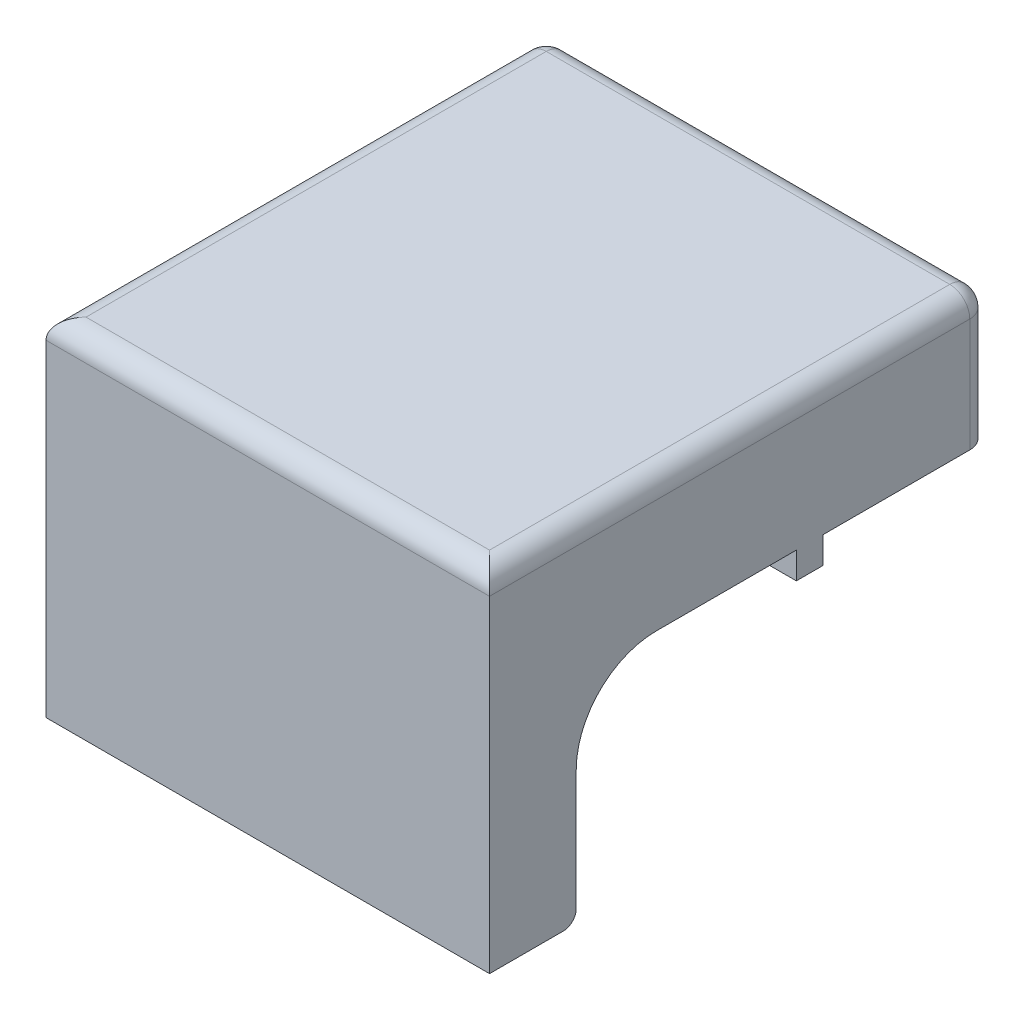
from build123d import *

# Parameters (mm, degrees)
BOSS_EXTRUDE1_DEPTH      = 10
BOSS_EXTRUDE2_DEPTH      = 42
BOSS_EXTRUDE2_DEPTH_BACK = 10
BOSS_EXTRUDE3_DEPTH      = 10
SKETCH3_R                = 20.035
CUT_EXTRUDE2_DEPTH       = 10
FILLET1_R                = 12
SKETCH9_W                = 7.5
SKETCH9_H                = 4
BOSS_EXTRUDE5_DEPTH      = 4
FILLET4_R                = 1.95
FILLET5_R                = 3
FILLET6_R                = 3
SKETCH10_R               = 3
CUT_EXTRUDE3_DEPTH       = 10


with BuildPart() as part:
    # Sketch1 → Boss-Extrude1 (new body)
    with BuildSketch(Plane(origin=(0, 0, 0), x_dir=(1, 0, 0), z_dir=(0, 1, 0))):
        Polygon((0, 0), (-43.5, 0), (-43.5, -68), (23, -68), (23, 0), align=None)
    extrude(amount=BOSS_EXTRUDE1_DEPTH)

    # Sketch2 → Boss-Extrude2 (add, two sides)
    with BuildSketch(Plane.XZ) as boss_extrude2_sk:
        Polygon((-43.5, 68), (-43.5, 62), (23, 62), (23, 68), (23, 75), (-43.5, 75), align=None)
    extrude(amount=BOSS_EXTRUDE2_DEPTH)
    extrude(boss_extrude2_sk.sketch, amount=-BOSS_EXTRUDE2_DEPTH_BACK)

    # Sketch4 → Boss-Extrude3 (add)
    with BuildSketch(Plane.XZ):
        Polygon((-43.5, 62), (-36, 62), (-36, 7.5), (15.5, 7.5), (15.5, 62), (23, 62), (23, 0), (-43.5, 0), align=None)
    extrude(amount=BOSS_EXTRUDE3_DEPTH)

    # Sketch3 → Cut-Extrude2 (cut)
    with BuildSketch(Plane(origin=(0, 0, 0), x_dir=(-1, 0, 0), z_dir=(0, 0, -1))):
        with Locations((16, -22)):
            Circle(SKETCH3_R)
    extrude(amount=-CUT_EXTRUDE2_DEPTH, mode=Mode.SUBTRACT)

    # Fillet1
    fillet1_edges = [part.edges().sort_by_distance(p)[0] for p in [
        (19.25, -10, 62),
        (-39.75, -10, 62),
    ]]
    fillet(fillet1_edges, radius=FILLET1_R)

    # Sketch9 → Boss-Extrude5 (add)
    with BuildSketch(Plane.XZ.offset(10)):
        with Locations((-39.75, 27)):
            Rectangle(SKETCH9_W, SKETCH9_H)
        with Locations((19.25, 27)):
            Rectangle(SKETCH9_W, SKETCH9_H)
    extrude(amount=BOSS_EXTRUDE5_DEPTH)

    # Fillet4
    fillet4_edges = [part.edges().sort_by_distance(p)[0] for p in [
        (-10.25, -42, 62),
    ]]
    fillet(fillet4_edges, radius=FILLET4_R)

    # Fillet5
    fillet5_edges = [part.edges().sort_by_distance(p)[0] for p in [
        (23, 0, 0),
        (-43.5, 0, 0),
    ]]
    fillet(fillet5_edges, radius=FILLET5_R)

    # Fillet6
    fillet6_edges = [part.edges().sort_by_distance(p)[0] for p in [
        (-10.25, 10, 0),
        (-43.5, 10, 39),
        (-42.621320344, 10, 0.878679656),
        (22.121320344, 10, 0.878679656),
        (23, 10, 39),
        (-10.25, 10, 75),
    ]]
    fillet(fillet6_edges, radius=FILLET6_R)

    # Sketch10 → Cut-Extrude3 (cut)
    with BuildSketch(Plane.XZ.offset(42)):
        with Locations((-28.5, 68)):
            Circle(SKETCH10_R)
        with Locations((5.5, 68)):
            Circle(SKETCH10_R)
    extrude(amount=-CUT_EXTRUDE3_DEPTH, mode=Mode.SUBTRACT)


solid = part.part
